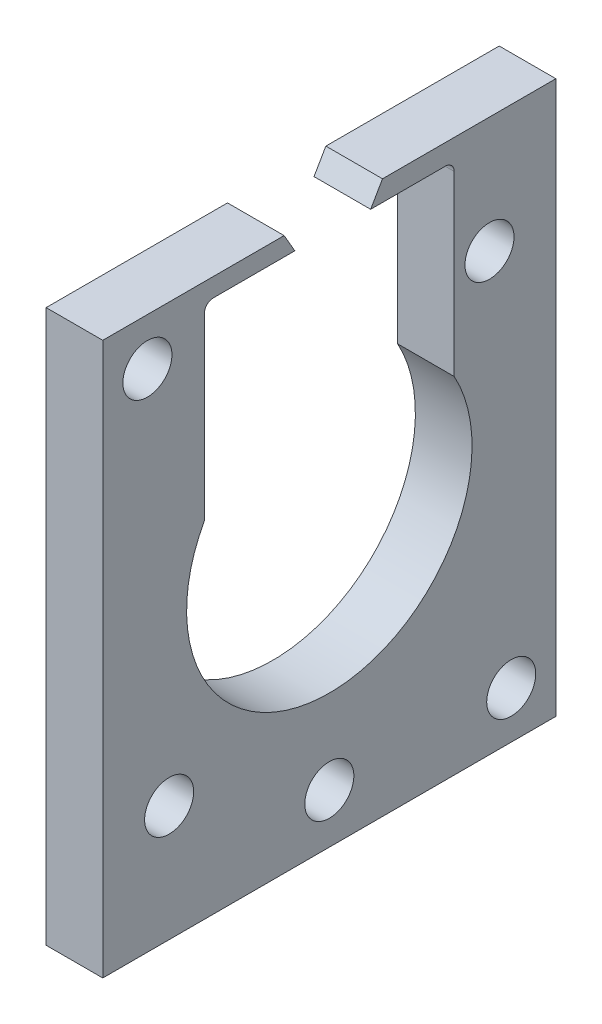
from build123d import *

# Parameters (mm, degrees)
SKETCH1_W           = 50.8
SKETCH1_H           = 61.92
BOSS_EXTRUDE2_DEPTH = 6.35
SKETCH2_R           = 16
CUT_EXTRUDE1_DEPTH  = 7.35
CUT_EXTRUDE4_DEPTH  = 7.35
CUT_EXTRUDE5_REACH  = 8.35
SKETCH5_R           = 2.75
FILLET1_R           = 1


with BuildPart() as part:
    # Sketch1 → Boss-Extrude2 (new body)
    with BuildSketch(Plane(origin=(0, 0, 0), x_dir=(0, 0, -1), z_dir=(1, 0, 0))):
        with Locations((25.4, 30.96)):
            Rectangle(SKETCH1_W, SKETCH1_H)
    extrude(amount=BOSS_EXTRUDE2_DEPTH)

    # Sketch2 → Cut-Extrude1 (cut, through all)
    with BuildSketch(Plane.ZY):
        with Locations((-25.4, 30.960695)):
            Circle(SKETCH2_R)
    extrude(amount=-CUT_EXTRUDE1_DEPTH, mode=Mode.SUBTRACT)

    # Sketch4 → Cut-Extrude4 (cut, through all)
    with BuildSketch(Plane(origin=(6.35, 0, 0), x_dir=(0, 0, -1), z_dir=(1, 0, 0))):
        Polygon((11.4, 59.839253392), (11.4, 37.92), (39.4, 37.92), (39.4, 59.62), (30.034684812, 59.62), (33.389978254, 65.431538715), (18.305977376, 65.431538715), (21.534684812, 59.839253392), align=None)
    extrude(amount=-CUT_EXTRUDE4_DEPTH, mode=Mode.SUBTRACT)

    # Sketch5 → Cut-Extrude5 (cut, up to next)
    with BuildSketch(Plane.ZY, mode=Mode.PRIVATE) as cut_extrude5_sk1:
        with Locations((-45.795509398, 5.272471121)):
            Circle(SKETCH5_R)
    cut_extrude5_tool1 = extrude(cut_extrude5_sk1.sketch, amount=-CUT_EXTRUDE5_REACH, mode=Mode.PRIVATE) & part.part
    add(cut_extrude5_tool1.solids().sort_by_distance((0, 5.272471, -45.795509))[0], mode=Mode.SUBTRACT)
    # Sketch5 → Cut-Extrude5 (cut, up to next)
    with BuildSketch(Plane.ZY, mode=Mode.PRIVATE) as cut_extrude5_sk2:
        with Locations((-25.399655405, 5.560695)):
            Circle(SKETCH5_R)
    cut_extrude5_tool2 = extrude(cut_extrude5_sk2.sketch, amount=-CUT_EXTRUDE5_REACH, mode=Mode.PRIVATE) & part.part
    add(cut_extrude5_tool2.solids().sort_by_distance((0, 5.560695, -25.399655))[0], mode=Mode.SUBTRACT)
    # Sketch5 → Cut-Extrude5 (cut, up to next)
    with BuildSketch(Plane.ZY, mode=Mode.PRIVATE) as cut_extrude5_sk3:
        with Locations((-7.439487758, 13.000182758)):
            Circle(SKETCH5_R)
    cut_extrude5_tool3 = extrude(cut_extrude5_sk3.sketch, amount=-CUT_EXTRUDE5_REACH, mode=Mode.PRIVATE) & part.part
    add(cut_extrude5_tool3.solids().sort_by_distance((0, 13.000183, -7.439488))[0], mode=Mode.SUBTRACT)
    # Sketch5 → Cut-Extrude5 (cut, up to next)
    with BuildSketch(Plane.ZY, mode=Mode.PRIVATE) as cut_extrude5_sk4:
        with Locations((-43.35992398, 48.920755906)):
            Circle(SKETCH5_R)
    cut_extrude5_tool4 = extrude(cut_extrude5_sk4.sketch, amount=-CUT_EXTRUDE5_REACH, mode=Mode.PRIVATE) & part.part
    add(cut_extrude5_tool4.solids().sort_by_distance((0, 48.920756, -43.359924))[0], mode=Mode.SUBTRACT)
    # Sketch5 → Cut-Extrude5 (cut, up to next)
    with BuildSketch(Plane.ZY, mode=Mode.PRIVATE) as cut_extrude5_sk5:
        with Locations((-5.004504526, 56.648087135)):
            Circle(SKETCH5_R)
    cut_extrude5_tool5 = extrude(cut_extrude5_sk5.sketch, amount=-CUT_EXTRUDE5_REACH, mode=Mode.PRIVATE) & part.part
    add(cut_extrude5_tool5.solids().sort_by_distance((0, 56.648087, -5.004505))[0], mode=Mode.SUBTRACT)

    # Fillet1
    fillet1_edges = [part.edges().sort_by_distance(p)[0] for p in [
        (3.175, 59.62, -39.4),
        (3.175, 59.839253392, -11.4),
    ]]
    fillet(fillet1_edges, radius=FILLET1_R)


solid = part.part
